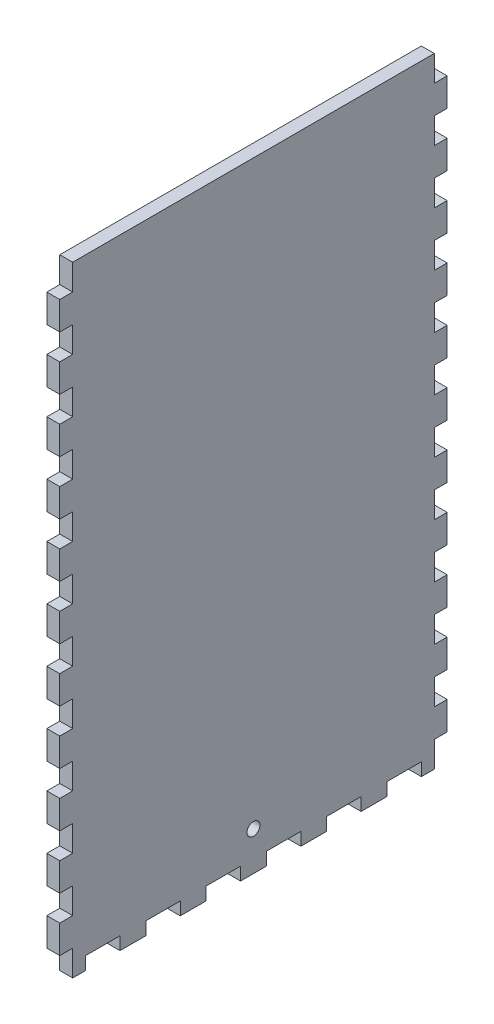
from build123d import *

# Parameters (mm, degrees)
SKETCH1_W           = 508
SKETCH1_H           = 190.5
BOSS_EXTRUDE1_DEPTH = 6.35
SKETCH2_W           = 508
SKETCH2_H           = 190.5
SKETCH2_W_2         = 495.3
SKETCH2_H_2         = 177.8
BOSS_EXTRUDE2_DEPTH = 298.45
SKETCH3_W           = 6.35
SKETCH3_H           = 16.933333333
SKETCH3_H_2         = 16.933333334
CUT_EXTRUDE1_DEPTH  = 12.7
SKETCH4_W           = 6.35
SKETCH4_H           = 15.875
CUT_EXTRUDE2_DEPTH  = 6.35
SKETCH6_W           = 514.801062296
SKETCH6_H           = 254.881465808
CUT_EXTRUDE5_DEPTH  = 305.8
SKETCH5_W           = 6.35
SKETCH5_H           = 16.933333333
SKETCH5_H_2         = 16.933333334
CUT_EXTRUDE6_DEPTH  = 6.35
SKETCH7_W           = 6.35
SKETCH7_H           = 12.7
CUT_EXTRUDE7_DEPTH  = 7.35
SKETCH8_R           = 3.175
CUT_EXTRUDE8_DEPTH  = 7.35


with BuildPart() as part:
    # Sketch1 → Boss-Extrude1 (new body)
    with BuildSketch(Plane(origin=(0, 0, 0), x_dir=(1, 0, 0), z_dir=(0, 1, 0))):
        Rectangle(SKETCH1_W, SKETCH1_H)
    extrude(amount=BOSS_EXTRUDE1_DEPTH)

    # Sketch2 → Boss-Extrude2 (add)
    with BuildSketch(Plane(origin=(0, 6.35, 0), x_dir=(1, 0, 0), z_dir=(0, 1, 0))):
        Rectangle(SKETCH2_W, SKETCH2_H)
        Rectangle(SKETCH2_W_2, SKETCH2_H_2, mode=Mode.SUBTRACT)
    extrude(amount=BOSS_EXTRUDE2_DEPTH)

    # Sketch3 → Cut-Extrude1 (cut)
    with BuildSketch(Plane.XY.offset(95.25)):
        with BuildLine():
            Line((-3.302, 283.21), (-3.302, 6.35))
            Line((-3.302, 6.35), (3.302, 6.35))
            Line((3.302, 6.35), (3.302, 292.354))
            Line((3.302, 292.354), (-16.256, 292.354))
            Line((-16.256, 292.354), (-16.256, 285.75))
            Line((-16.256, 285.75), (-5.842, 285.75))
            ThreePointArc((-5.842, 285.75), (-4.045948776, 285.006051224), (-3.302, 283.21))
        make_face()
        with Locations((12.827, 80.433333334)):
            Rectangle(SKETCH3_W, SKETCH3_H)
        with Locations((12.827, 50.8)):
            Rectangle(SKETCH3_W, SKETCH3_H_2)
        with Locations((12.827, 21.166666667)):
            Rectangle(SKETCH3_W, SKETCH3_H)
    extrude(amount=-CUT_EXTRUDE1_DEPTH, mode=Mode.SUBTRACT)

    # Sketch4 → Cut-Extrude2 (cut)
    with BuildSketch(Plane.XY.offset(-88.9)):
        with Locations((-19.431, 284.1625)):
            Rectangle(SKETCH4_W, SKETCH4_H)
        with Locations((-19.431, 255.5875)):
            Rectangle(SKETCH4_W, SKETCH4_H)
        with Locations((-19.431, 227.0125)):
            Rectangle(SKETCH4_W, SKETCH4_H)
        with Locations((-19.431, 198.4375)):
            Rectangle(SKETCH4_W, SKETCH4_H)
        with Locations((-19.431, 169.8625)):
            Rectangle(SKETCH4_W, SKETCH4_H)
        with Locations((-19.431, 141.2875)):
            Rectangle(SKETCH4_W, SKETCH4_H)
        with Locations((-19.431, 112.7125)):
            Rectangle(SKETCH4_W, SKETCH4_H)
        with Locations((-19.431, 84.1375)):
            Rectangle(SKETCH4_W, SKETCH4_H)
        with Locations((-19.431, 55.5625)):
            Rectangle(SKETCH4_W, SKETCH4_H)
        with Locations((-19.431, 26.9875)):
            Rectangle(SKETCH4_W, SKETCH4_H)
    cut_extrude2 = extrude(amount=-CUT_EXTRUDE2_DEPTH, mode=Mode.SUBTRACT)

    # Mirror1: Cut-Extrude2 across plane
    add(cut_extrude2.mirror(Plane.ZY.offset(6.477)), mode=Mode.SUBTRACT)

    # Sketch6 → Cut-Extrude5 (cut, through all)
    with BuildSketch(Plane(origin=(0, 0, 0), x_dir=(1, 0, 0), z_dir=(0, 1, 0))):
        with Locations((9.750531148, -10.000845247)):
            Rectangle(SKETCH6_W, SKETCH6_H)
    extrude(amount=CUT_EXTRUDE5_DEPTH, mode=Mode.SUBTRACT)

    # Sketch5 → Cut-Extrude6 (cut)
    with BuildSketch(Plane(origin=(0, 0, 0), x_dir=(-1, 0, 0), z_dir=(0, -1, 0))):
        with Locations((250.825, -74.083333334)):
            Rectangle(SKETCH5_W, SKETCH5_H)
        with Locations((250.825, -44.45)):
            Rectangle(SKETCH5_W, SKETCH5_H_2)
        with Locations((250.825, -14.816666667)):
            Rectangle(SKETCH5_W, SKETCH5_H)
        with Locations((250.825, 14.816666667)):
            Rectangle(SKETCH5_W, SKETCH5_H)
        with Locations((250.825, 44.45)):
            Rectangle(SKETCH5_W, SKETCH5_H_2)
        with Locations((250.825, 74.083333334)):
            Rectangle(SKETCH5_W, SKETCH5_H)
    extrude(amount=-CUT_EXTRUDE6_DEPTH, mode=Mode.SUBTRACT)

    # Sketch7 → Cut-Extrude7 (cut, through all)
    with BuildSketch(Plane.ZY.offset(254)):
        with Locations((-92.075, 32.904545455)):
            Rectangle(SKETCH7_W, SKETCH7_H)
        with Locations((-92.075, 6.35)):
            Rectangle(SKETCH7_W, SKETCH7_H)
        with Locations((-92.075, 59.459090909)):
            Rectangle(SKETCH7_W, SKETCH7_H)
        with Locations((-92.075, 86.013636364)):
            Rectangle(SKETCH7_W, SKETCH7_H)
        with Locations((-92.075, 112.568181818)):
            Rectangle(SKETCH7_W, SKETCH7_H)
        with Locations((-92.075, 139.122727273)):
            Rectangle(SKETCH7_W, SKETCH7_H)
        with Locations((-92.075, 165.677272727)):
            Rectangle(SKETCH7_W, SKETCH7_H)
        with Locations((-92.075, 192.231818182)):
            Rectangle(SKETCH7_W, SKETCH7_H)
        with Locations((-92.075, 218.786363636)):
            Rectangle(SKETCH7_W, SKETCH7_H)
        with Locations((-92.075, 245.340909091)):
            Rectangle(SKETCH7_W, SKETCH7_H)
        with Locations((-92.075, 271.895454545)):
            Rectangle(SKETCH7_W, SKETCH7_H)
        with Locations((-92.075, 298.45)):
            Rectangle(SKETCH7_W, SKETCH7_H)
        with Locations((92.075, 298.45)):
            Rectangle(SKETCH7_W, SKETCH7_H)
        with Locations((92.075, 271.895454545)):
            Rectangle(SKETCH7_W, SKETCH7_H)
        with Locations((92.075, 245.340909091)):
            Rectangle(SKETCH7_W, SKETCH7_H)
        with Locations((92.075, 218.786363636)):
            Rectangle(SKETCH7_W, SKETCH7_H)
        with Locations((92.075, 192.231818182)):
            Rectangle(SKETCH7_W, SKETCH7_H)
        with Locations((92.075, 165.677272727)):
            Rectangle(SKETCH7_W, SKETCH7_H)
        with Locations((92.075, 139.122727273)):
            Rectangle(SKETCH7_W, SKETCH7_H)
        with Locations((92.075, 112.568181818)):
            Rectangle(SKETCH7_W, SKETCH7_H)
        with Locations((92.075, 86.013636364)):
            Rectangle(SKETCH7_W, SKETCH7_H)
        with Locations((92.075, 59.459090909)):
            Rectangle(SKETCH7_W, SKETCH7_H)
        with Locations((92.075, 32.904545455)):
            Rectangle(SKETCH7_W, SKETCH7_H)
        with Locations((92.075, 6.35)):
            Rectangle(SKETCH7_W, SKETCH7_H)
    extrude(amount=-CUT_EXTRUDE7_DEPTH, mode=Mode.SUBTRACT)

    # Sketch8 → Cut-Extrude8 (cut, through all)
    with BuildSketch(Plane.ZY.offset(254)):
        with Locations((0, 19.05)):
            Circle(SKETCH8_R)
    extrude(amount=-CUT_EXTRUDE8_DEPTH, mode=Mode.SUBTRACT)


solid = part.part
